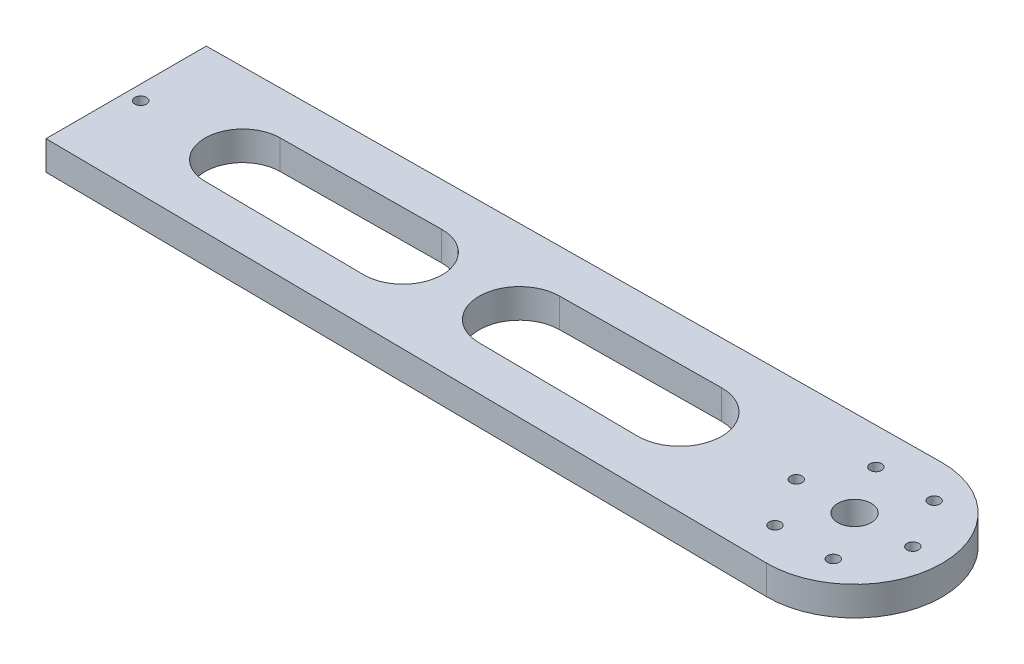
from build123d import *

# Parameters (mm, degrees)
SKETCH1_R           = 5.75
SKETCH1_R_2         = 2
BOSS_EXTRUDE1_DEPTH = 10


with BuildPart() as part:
    # Sketch1 → Boss-Extrude1 (new body)
    with BuildSketch(Plane(origin=(0, 0, 0), x_dir=(1, 0, 0), z_dir=(0, 1, 0))):
        with BuildLine():
            Line((-216.382104852, 37.479356926), (33.317969978, 39.953751753))
            ThreePointArc((33.317969978, 39.953751753), (63.615239274, 9.952328714), (33.312178481, -20.043244588))
            Line((33.312178481, -20.043244588), (-216.38741399, -17.520642817))
            Line((-216.38741399, -17.520642817), (-216.382104852, 37.479356926))
        make_face()
        with Locations((33.615239414, 9.955224607)):
            Circle(SKETCH1_R, mode=Mode.SUBTRACT)
        with Locations((53.615239414, 9.955224607)):
            Circle(SKETCH1_R_2, mode=Mode.SUBTRACT)
        with Locations((43.615239414, -7.365283468)):
            Circle(SKETCH1_R_2, mode=Mode.SUBTRACT)
        with Locations((23.615239414, -7.365283468)):
            Circle(SKETCH1_R_2, mode=Mode.SUBTRACT)
        with Locations((13.615239414, 9.955224607)):
            Circle(SKETCH1_R_2, mode=Mode.SUBTRACT)
        with Locations((23.615239414, 27.275732683)):
            Circle(SKETCH1_R_2, mode=Mode.SUBTRACT)
        with Locations((43.615239414, 27.275732683)):
            Circle(SKETCH1_R_2, mode=Mode.SUBTRACT)
        with Locations((-211.384759398, 9.979356926)):
            Circle(SKETCH1_R_2, mode=Mode.SUBTRACT)
        with BuildLine():
            Line((-176.512574007, 22.873706291), (-121.518027204, 23.418672976))
            ThreePointArc((-121.518027204, 23.418672976), (-107.935613387, 9.968888481), (-121.52062356, -3.478273548))
            Line((-121.52062356, -3.478273548), (-176.515064128, -2.922689649))
            ThreePointArc((-176.515064128, -2.922689649), (-189.283603246, 9.976740986), (-176.512574007, 22.873706291))
        make_face(mode=Mode.SUBTRACT)
        with BuildLine():
            Line((-81.524666784, -3.882334565), (-26.530226217, -4.437918464))
            ThreePointArc((-26.530226217, -4.437918464), (-11.985090745, 9.959626398), (-26.527446362, 24.359979069))
            Line((-26.527446362, 24.359979069), (-81.521993165, 23.815012384))
            ThreePointArc((-81.521993165, 23.815012384), (-95.234126773, 9.967662409), (-81.524666784, -3.882334565))
        make_face(mode=Mode.SUBTRACT)
    extrude(amount=BOSS_EXTRUDE1_DEPTH)


solid = part.part
